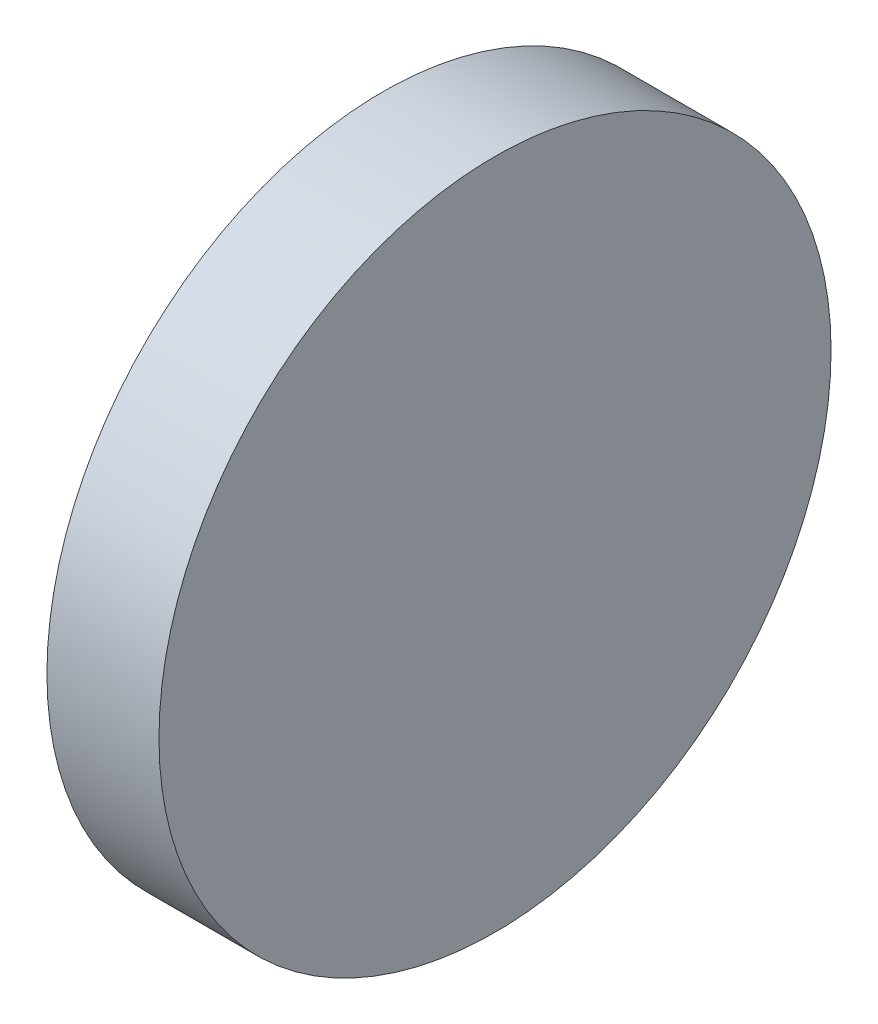
from build123d import *

# Parameters (mm, degrees)
SKETCH1_R           = 15
BOSS_EXTRUDE1_DEPTH = 5


with BuildPart() as part:
    # Sketch1 → Boss-Extrude1 (new body)
    with BuildSketch(Plane(origin=(0, 0, 0), x_dir=(0, 0, -1), z_dir=(1, 0, 0))):
        Circle(SKETCH1_R)
    extrude(amount=BOSS_EXTRUDE1_DEPTH)


solid = part.part
